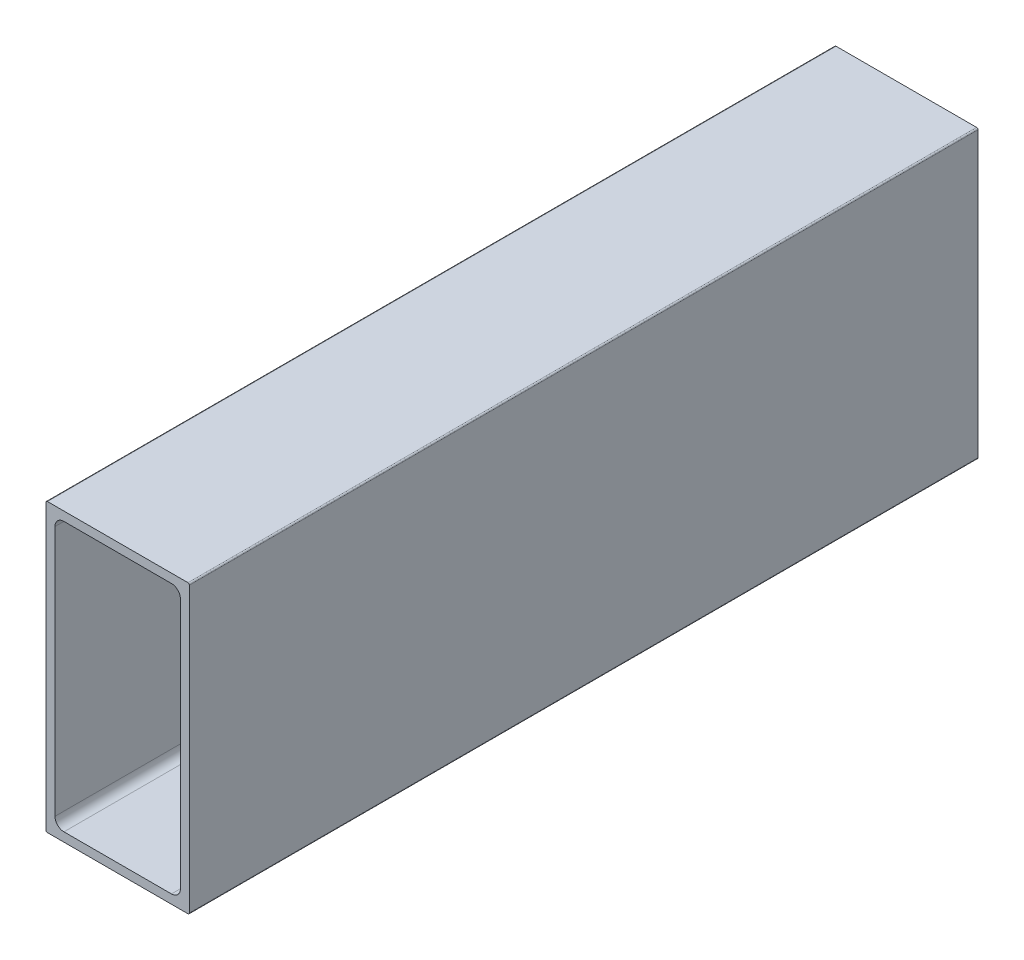
from build123d import *

# Parameters (mm, degrees)
BOSS_EXTRUDE1_DEPTH = 139.7


with BuildPart() as part:
    # Sketch1 → Boss-Extrude1 (new body)
    with BuildSketch(Plane(origin=(0, 0, 0), x_dir=(-1, 0, 0), z_dir=(0, 0, -1))):
        with BuildLine():
            Line((-12.7, 25.146), (-12.7, -25.146))
            ThreePointArc((-12.7, -25.146), (-12.625605122, -25.325605122), (-12.446, -25.4))
            Line((-12.446, -25.4), (12.446, -25.4))
            ThreePointArc((12.446, -25.4), (12.625605122, -25.325605122), (12.7, -25.146))
            Line((12.7, -25.146), (12.7, 25.146))
            ThreePointArc((12.7, 25.146), (12.625605122, 25.325605122), (12.446, 25.4))
            Line((12.446, 25.4), (-12.446, 25.4))
            ThreePointArc((-12.446, 25.4), (-12.625605122, 25.325605122), (-12.7, 25.146))
        make_face()
        with BuildLine():
            Line((-11.1125, -22.225), (-11.1125, 22.225))
            ThreePointArc((-11.1125, 22.225), (-10.647532015, 23.347532015), (-9.525, 23.8125))
            Line((-9.525, 23.8125), (9.525, 23.8125))
            ThreePointArc((9.525, 23.8125), (10.647532015, 23.347532015), (11.1125, 22.225))
            Line((11.1125, 22.225), (11.1125, -22.225))
            ThreePointArc((11.1125, -22.225), (10.647532015, -23.347532015), (9.525, -23.8125))
            Line((9.525, -23.8125), (-9.525, -23.8125))
            ThreePointArc((-9.525, -23.8125), (-10.647532015, -23.347532015), (-11.1125, -22.225))
        make_face(mode=Mode.SUBTRACT)
    extrude(amount=-BOSS_EXTRUDE1_DEPTH)


solid = part.part
